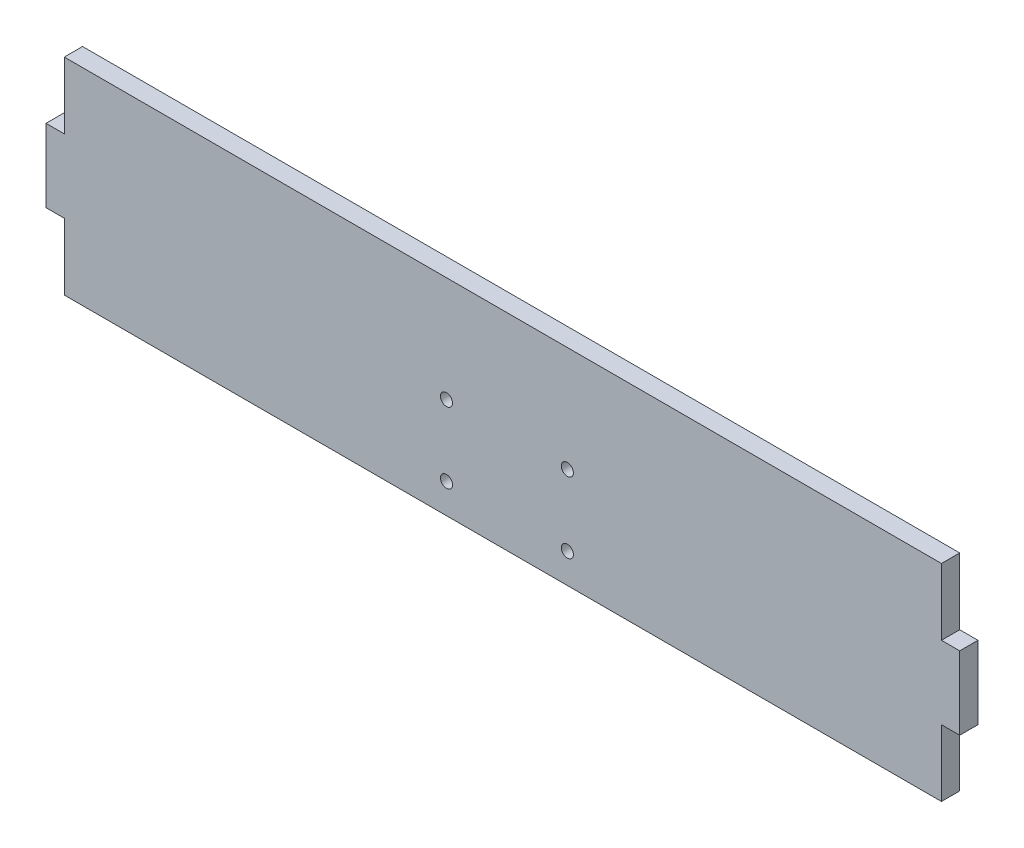
from build123d import *

# Parameters (mm, degrees)
SKETCH1_W           = 158.75
SKETCH1_H           = 35.814
BOSS_EXTRUDE1_DEPTH = 3.175
SKETCH2_W           = 3.175
SKETCH2_H           = 11.557
CUT_EXTRUDE1_DEPTH  = 4.175
SKETCH3_R           = 1.05
CUT_EXTRUDE2_DEPTH  = 4.175


with BuildPart() as part:
    # Sketch1 → Boss-Extrude1 (new body)
    with BuildSketch(Plane.XY):
        with Locations((79.375, 17.907)):
            Rectangle(SKETCH1_W, SKETCH1_H)
    extrude(amount=BOSS_EXTRUDE1_DEPTH)

    # Sketch2 → Cut-Extrude1 (cut, through all)
    with BuildSketch(Plane.XY.offset(3.175)):
        with Locations((157.1625, 5.7785)):
            Rectangle(SKETCH2_W, SKETCH2_H)
        with Locations((1.5875, 5.7785)):
            Rectangle(SKETCH2_W, SKETCH2_H)
        with Locations((1.5875, 30.0355)):
            Rectangle(SKETCH2_W, SKETCH2_H)
        with Locations((157.1625, 30.0355)):
            Rectangle(SKETCH2_W, SKETCH2_H)
    extrude(amount=-CUT_EXTRUDE1_DEPTH, mode=Mode.SUBTRACT)

    # Sketch3 → Cut-Extrude2 (cut, through all)
    with BuildSketch(Plane(origin=(0, 0, 0), x_dir=(-1, 0, 0), z_dir=(0, 0, -1))):
        with Locations((-90.578925545, 17.471786094)):
            Circle(SKETCH3_R)
        with Locations((-69.578925545, 5.171786094)):
            Circle(SKETCH3_R)
        with Locations((-90.578925545, 5.171786094)):
            Circle(SKETCH3_R)
        with Locations((-69.578925545, 17.471786094)):
            Circle(SKETCH3_R)
    extrude(amount=-CUT_EXTRUDE2_DEPTH, mode=Mode.SUBTRACT)


solid = part.part
